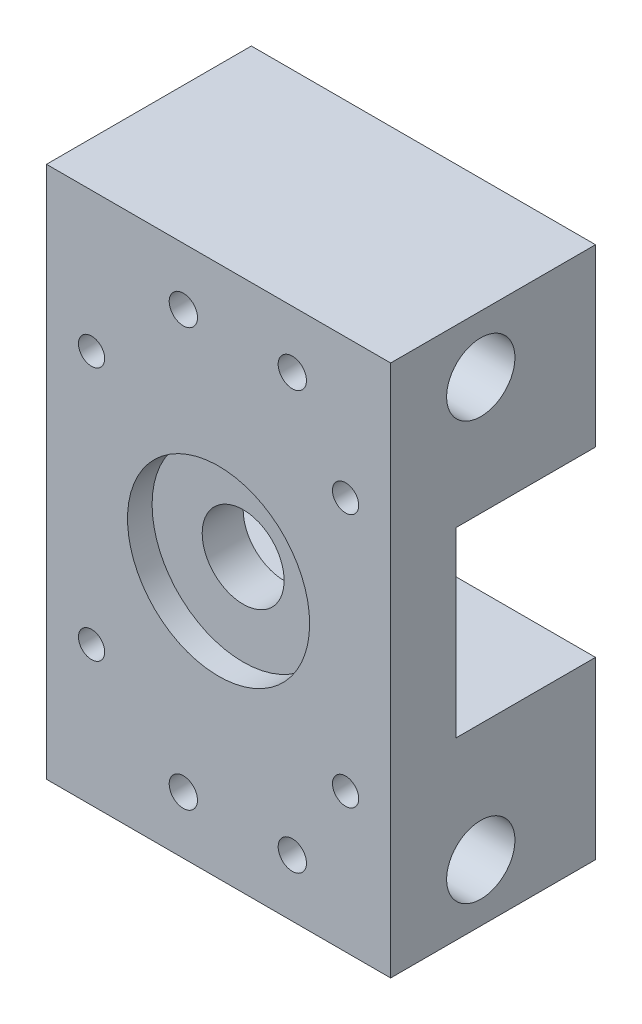
from build123d import *

# Parameters (mm, degrees)
ESBO_O1_W                                            = 42
ESBO_O1_H                                            = 65
RESSALTO_EXTRUS_O1_DEPTH                             = 21
ESBO_O2_W                                            = 17
ESBO_O2_H                                            = 22.225
CORTE_EXTRUS_O1_DEPTH                                = 43
FURO_COM_FOLGA_DE_M31_D                              = 3.4544
FURO_COM_FOLGA_DE_M31_DEPTH                          = 21
FURO_COM_FOLGA_DE_M201_D                             = 22.225
FURO_COM_FOLGA_DE_M201_DEPTH                         = 21
REBAIXO_PARA_PARAFUSO_DE_M_QUINA_DE_CABE_D           = 3.2
REBAIXO_PARA_PARAFUSO_DE_M_QUINA_DE_CABE_DEPTH       = 21
REBAIXO_PARA_PARAFUSO_DE_M_QUINA_DE_CABE_CBORE_D     = 6
REBAIXO_PARA_PARAFUSO_DE_M_QUINA_DE_CABE_CBORE_DEPTH = 7.62
FURO1_D                                              = 8.334375
FURO1_DEPTH                                          = 8
ESBO_O11_W                                           = 42
ESBO_O11_H                                           = 65
ESBO_O11_R                                           = 11.1125
ESBO_O11_R_2                                         = 1.7272
ESBO_O11_R_3                                         = 1.6
RESSALTO_EXTRUS_O2_DEPTH                             = 4
ESBO_O13_R                                           = 11.1125
ESBO_O13_R_2                                         = 5
RESSALTO_EXTRUS_O3_DEPTH                             = 5


with BuildPart() as part:
    # Esboço1 → Ressalto-extrusão1 (new body)
    with BuildSketch(Plane.XY.offset(21)):
        with Locations((21, 32.5)):
            Rectangle(ESBO_O1_W, ESBO_O1_H)
    extrude(amount=-RESSALTO_EXTRUS_O1_DEPTH)

    # Esboço2 → Corte-extrusão1 (cut, through all)
    with BuildSketch(Plane(origin=(42, 0, 0), x_dir=(0, 0, -1), z_dir=(1, 0, 0))):
        with Locations((-8.5, 32.5)):
            Rectangle(ESBO_O2_W, ESBO_O2_H)
    extrude(amount=-CORTE_EXTRUS_O1_DEPTH, mode=Mode.SUBTRACT)

    # Furo com folga de M31
    with Locations(Plane(origin=(0, 0, 0), x_dir=(-1, 0, 0), z_dir=(0, 0, -1))):
        with Locations((-30, 7), (-16.7, 7), (-16.7, 58), (-30, 58)):
            Hole(FURO_COM_FOLGA_DE_M31_D / 2, depth=FURO_COM_FOLGA_DE_M31_DEPTH)

    # Furo com folga de M201
    with Locations(Plane.XY.offset(21)):
        with Locations((21, 32.5)):
            Hole(FURO_COM_FOLGA_DE_M201_D / 2, depth=FURO_COM_FOLGA_DE_M201_DEPTH)

    # Rebaixo para parafuso de máquina de cabeça sextavada de M31
    with Locations(Plane(origin=(0, 0, 0), x_dir=(-1, 0, 0), z_dir=(0, 0, -1))):
        with Locations((-36.5, 17), (-5.5, 17), (-5.5, 48), (-36.5, 48)):
            CounterBoreHole(REBAIXO_PARA_PARAFUSO_DE_M_QUINA_DE_CABE_D / 2, REBAIXO_PARA_PARAFUSO_DE_M_QUINA_DE_CABE_CBORE_D / 2, REBAIXO_PARA_PARAFUSO_DE_M_QUINA_DE_CABE_CBORE_DEPTH, depth=REBAIXO_PARA_PARAFUSO_DE_M_QUINA_DE_CABE_DEPTH)

    # Furo1
    with Locations(Plane(origin=(42, 0, 0), x_dir=(0, 0, -1), z_dir=(1, 0, 0))):
        with Locations((-14, 7), (-14, 58)):
            Hole(FURO1_D / 2, depth=FURO1_DEPTH)

    # Esboço11 → Ressalto-extrusão2 (add)
    with BuildSketch(Plane.XY.offset(21)):
        with Locations((21, 32.5)):
            Rectangle(ESBO_O11_W, ESBO_O11_H)
        with Locations((21, 32.5)):
            Circle(ESBO_O11_R, mode=Mode.SUBTRACT)
        with Locations((16.7, 7)):
            Circle(ESBO_O11_R_2, mode=Mode.SUBTRACT)
        with Locations((30, 7)):
            Circle(ESBO_O11_R_2, mode=Mode.SUBTRACT)
        with Locations((5.5, 17)):
            Circle(ESBO_O11_R_3, mode=Mode.SUBTRACT)
        with Locations((5.5, 48)):
            Circle(ESBO_O11_R_3, mode=Mode.SUBTRACT)
        with Locations((16.7, 58)):
            Circle(ESBO_O11_R_2, mode=Mode.SUBTRACT)
        with Locations((36.5, 48)):
            Circle(ESBO_O11_R_3, mode=Mode.SUBTRACT)
        with Locations((30, 58)):
            Circle(ESBO_O11_R_2, mode=Mode.SUBTRACT)
        with Locations((36.5, 17)):
            Circle(ESBO_O11_R_3, mode=Mode.SUBTRACT)
    extrude(amount=RESSALTO_EXTRUS_O2_DEPTH)

    # Esboço13 → Ressalto-extrusão3 (add)
    with BuildSketch(Plane(origin=(0, 0, 17), x_dir=(-1, 0, 0), z_dir=(0, 0, -1))):
        with Locations((-21, 32.5)):
            Circle(ESBO_O13_R)
        with Locations((-21, 32.5)):
            Circle(ESBO_O13_R_2, mode=Mode.SUBTRACT)
    extrude(amount=-RESSALTO_EXTRUS_O3_DEPTH)


solid = part.part
